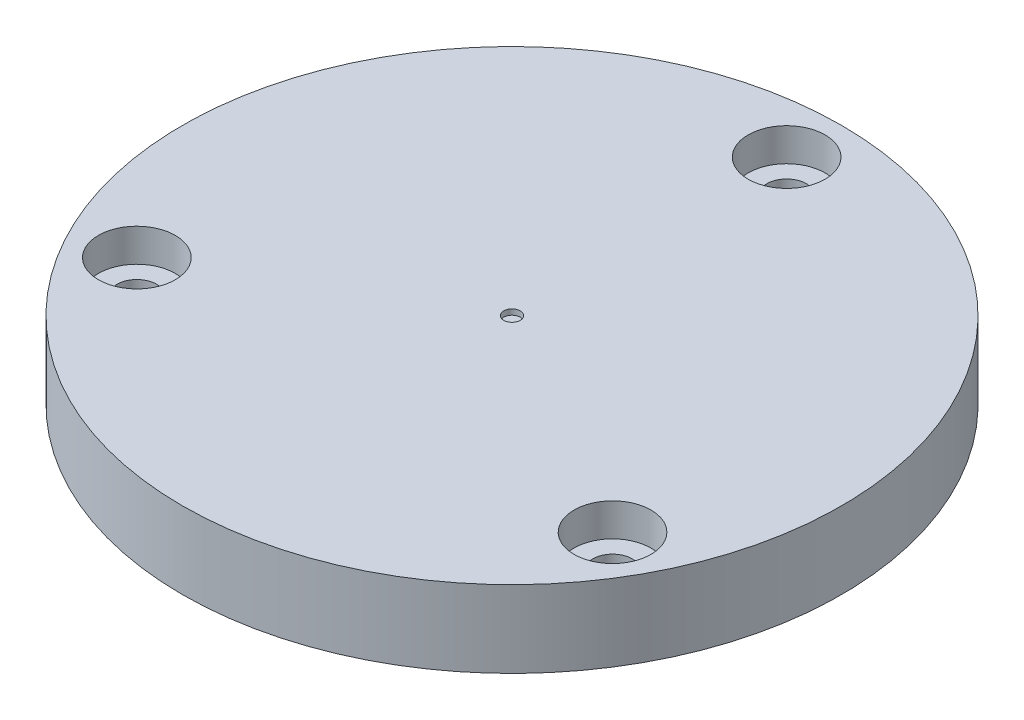
from build123d import *

# Parameters (mm, degrees)
SKETCH1_R           = 30
SKETCH1_R_2         = 1.8
BOSS_EXTRUDE1_DEPTH = 7
SKETCH2_R           = 3.5
CUT_EXTRUDE1_DEPTH  = 3
SKETCH3_R           = 0.75
CUT_EXTRUDE2_DEPTH  = 0.5


with BuildPart() as part:
    # Sketch1 → Boss-Extrude1 (new body)
    with BuildSketch(Plane(origin=(0, 0, 0), x_dir=(1, 0, 0), z_dir=(0, 1, 0))):
        Circle(SKETCH1_R)
        with Locations((0, 25)):
            Circle(SKETCH1_R_2, mode=Mode.SUBTRACT)
        with Locations((21.650635095, -12.5)):
            Circle(SKETCH1_R_2, mode=Mode.SUBTRACT)
        with Locations((-21.650635095, -12.5)):
            Circle(SKETCH1_R_2, mode=Mode.SUBTRACT)
    extrude(amount=BOSS_EXTRUDE1_DEPTH)

    # Sketch2 → Cut-Extrude1 (cut)
    with BuildSketch(Plane(origin=(0, 7, 0), x_dir=(1, 0, 0), z_dir=(0, 1, 0))):
        with Locations((0, 25)):
            Circle(SKETCH2_R)
        with Locations((21.650635095, -12.5)):
            Circle(SKETCH2_R)
        with Locations((-21.650635095, -12.5)):
            Circle(SKETCH2_R)
    extrude(amount=-CUT_EXTRUDE1_DEPTH, mode=Mode.SUBTRACT)

    # Sketch3 → Cut-Extrude2 (cut)
    with BuildSketch(Plane(origin=(0, 7, 0), x_dir=(1, 0, 0), z_dir=(0, 1, 0))):
        Circle(SKETCH3_R)
    extrude(amount=-CUT_EXTRUDE2_DEPTH, mode=Mode.SUBTRACT)


solid = part.part
